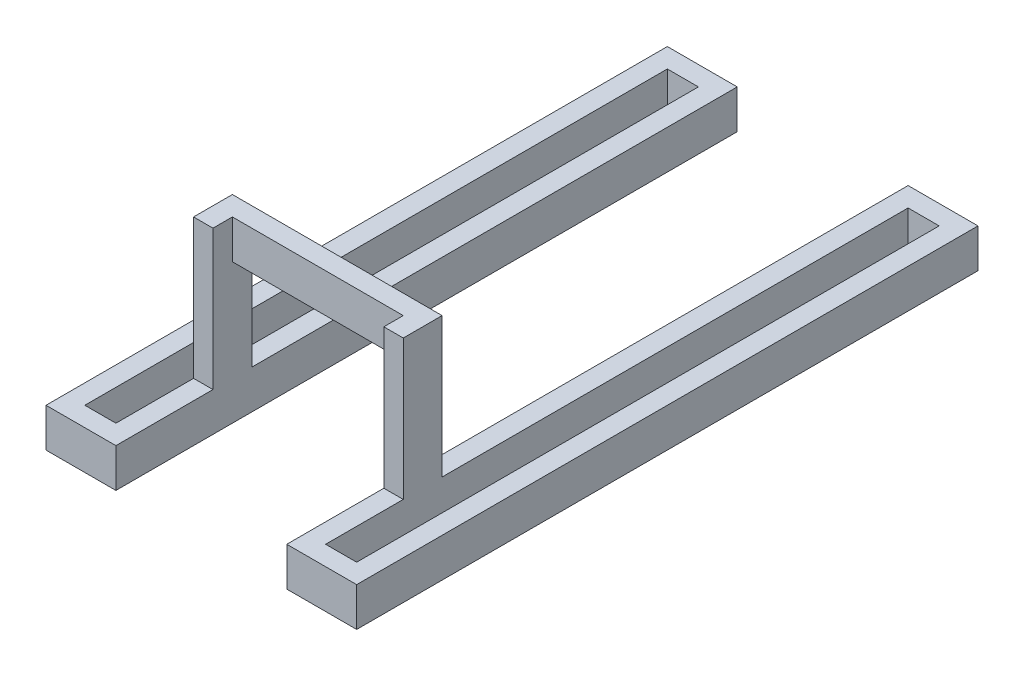
from build123d import *

# Parameters (mm, degrees)
CROQUIS2_W                 = 25
CROQUIS2_H                 = 50
SALIENTE_EXTRUIR1_DEPTH    = 800
SALIENTE_EXTRUIR1_2_DEPTH  = 800
SALIENTE_EXTRUIR1_3_DEPTH  = 800
SALIENTE_EXTRUIR1_4_DEPTH  = 800
CROQUIS3_W                 = 25
CROQUIS3_H                 = 50
SALIENTE_EXTRUIR2_DEPTH    = 230
CROQUIS4_W                 = 25
CROQUIS4_H                 = 50
SALIENTE_EXTRUIR3_DEPTH    = 65
CROQUIS5_W                 = 25
CROQUIS5_H                 = 50
SALIENTE_EXTRUIR4_DEPTH    = 65
CROQUIS6_W                 = 25
CROQUIS6_H                 = 50
SALIENTE_EXTRUIR5_DEPTH    = 800
CROQUIS7_W                 = 25
CROQUIS7_H                 = 50
SALIENTE_EXTRUIR6_DEPTH    = 270
CROQUIS8_W                 = 25
CROQUIS8_H                 = 50
SALIENTE_EXTRUIR7_DEPTH    = 180
CROQUIS9_W                 = 625
CROQUIS9_H                 = 180
CROQUIS9_W_2               = 125
CORTAR_EXTRUIR1_DEPTH      = 201
CORTAR_EXTRUIR1_DEPTH_BACK = 201


with BuildPart() as part:
    # Croquis2 → Saliente-Extruir1 (new body)
    with BuildSketch(Plane.XY):
        with Locations((-187.5, 25)):
            Rectangle(CROQUIS2_W, CROQUIS2_H)
    extrude(amount=SALIENTE_EXTRUIR1_DEPTH)



with BuildPart() as body_2:
    # Croquis2 → Saliente-Extruir1 2 (new body)
    with BuildSketch(Plane.XY):
        with Locations((187.5, 25)):
            Rectangle(CROQUIS2_W, CROQUIS2_H)
    extrude(amount=SALIENTE_EXTRUIR1_2_DEPTH)


with BuildPart() as body_3:
    # Croquis2 → Saliente-Extruir1 3 (new body)
    with BuildSketch(Plane.XY):
        with Locations((-122.5, 25)):
            Rectangle(CROQUIS2_W, CROQUIS2_H)
    extrude(amount=SALIENTE_EXTRUIR1_3_DEPTH)



with BuildPart() as body_4:
    # Croquis2 → Saliente-Extruir1 4 (new body)
    with BuildSketch(Plane.XY):
        with Locations((122.5, 25)):
            Rectangle(CROQUIS2_W, CROQUIS2_H)
    extrude(amount=SALIENTE_EXTRUIR1_4_DEPTH)


with BuildPart() as body_3_1:
    add(body_3.part)

    add(body_4.part)  # Saliente-Extruir2 merges body 4
    # Croquis3 → Saliente-Extruir2 (add)
    with BuildSketch(Plane.XZ):
        with Locations((-122.5, 775)):
            Rectangle(CROQUIS3_W, CROQUIS3_H)
        with Locations((122.5, 775)):
            Rectangle(CROQUIS3_W, CROQUIS3_H)
        with Locations((-122.5, 25)):
            Rectangle(CROQUIS3_W, CROQUIS3_H)
        with Locations((122.5, 25)):
            Rectangle(CROQUIS3_W, CROQUIS3_H)
    extrude(amount=-SALIENTE_EXTRUIR2_DEPTH)


with BuildPart() as part_1:
    add(part.part)

    add(body_3_1.part)  # Saliente-Extruir3 merges body 3
    # Croquis4 → Saliente-Extruir3 (add)
    with BuildSketch(Plane.ZY.offset(200)):
        with Locations((12.5, 25)):
            Rectangle(CROQUIS4_W, CROQUIS4_H)
        with Locations((787.5, 25)):
            Rectangle(CROQUIS4_W, CROQUIS4_H)
    extrude(amount=-SALIENTE_EXTRUIR3_DEPTH)


    add(body_2.part)  # Saliente-Extruir4 merges body 2
    # Croquis5 → Saliente-Extruir4 (add)
    with BuildSketch(Plane(origin=(200, 0, 0), x_dir=(0, 0, -1), z_dir=(1, 0, 0))):
        with Locations((-787.5, 25)):
            Rectangle(CROQUIS5_W, CROQUIS5_H)
        with Locations((-12.5, 25)):
            Rectangle(CROQUIS5_W, CROQUIS5_H)
    extrude(amount=-SALIENTE_EXTRUIR4_DEPTH)

    # Croquis6 → Saliente-Extruir5 (add)
    with BuildSketch(Plane.XY.offset(800)):
        with Locations((-122.5, 205)):
            Rectangle(CROQUIS6_W, CROQUIS6_H)
        with Locations((122.5, 205)):
            Rectangle(CROQUIS6_W, CROQUIS6_H)
    extrude(amount=-SALIENTE_EXTRUIR5_DEPTH)

    # Croquis7 → Saliente-Extruir6 (add)
    with BuildSketch(Plane(origin=(135, 0, 0), x_dir=(0, 0, -1), z_dir=(1, 0, 0))):
        with Locations((-637.5, 205)):
            Rectangle(CROQUIS7_W, CROQUIS7_H)
    extrude(amount=-SALIENTE_EXTRUIR6_DEPTH)

    # Croquis8 → Saliente-Extruir7 (add)
    with BuildSketch(Plane(origin=(0, 230, 0), x_dir=(1, 0, 0), z_dir=(0, 1, 0))):
        with Locations((-122.5, -650)):
            Rectangle(CROQUIS8_W, CROQUIS8_H)
        with Locations((122.5, -650)):
            Rectangle(CROQUIS8_W, CROQUIS8_H)
    extrude(amount=-SALIENTE_EXTRUIR7_DEPTH)

    # Croquis9 → Cortar-Extruir1 (cut, two sides)
    with BuildSketch(Plane(origin=(0, 0, 0), x_dir=(0, 0, -1), z_dir=(1, 0, 0))) as cortar_extruir1_sk:
        with Locations((-312.5, 140)):
            Rectangle(CROQUIS9_W, CROQUIS9_H)
        with Locations((-737.5, 140)):
            Rectangle(CROQUIS9_W_2, CROQUIS9_H)
    extrude(amount=CORTAR_EXTRUIR1_DEPTH, mode=Mode.SUBTRACT)
    extrude(cortar_extruir1_sk.sketch, amount=-CORTAR_EXTRUIR1_DEPTH_BACK, mode=Mode.SUBTRACT)


solid = part_1.part
